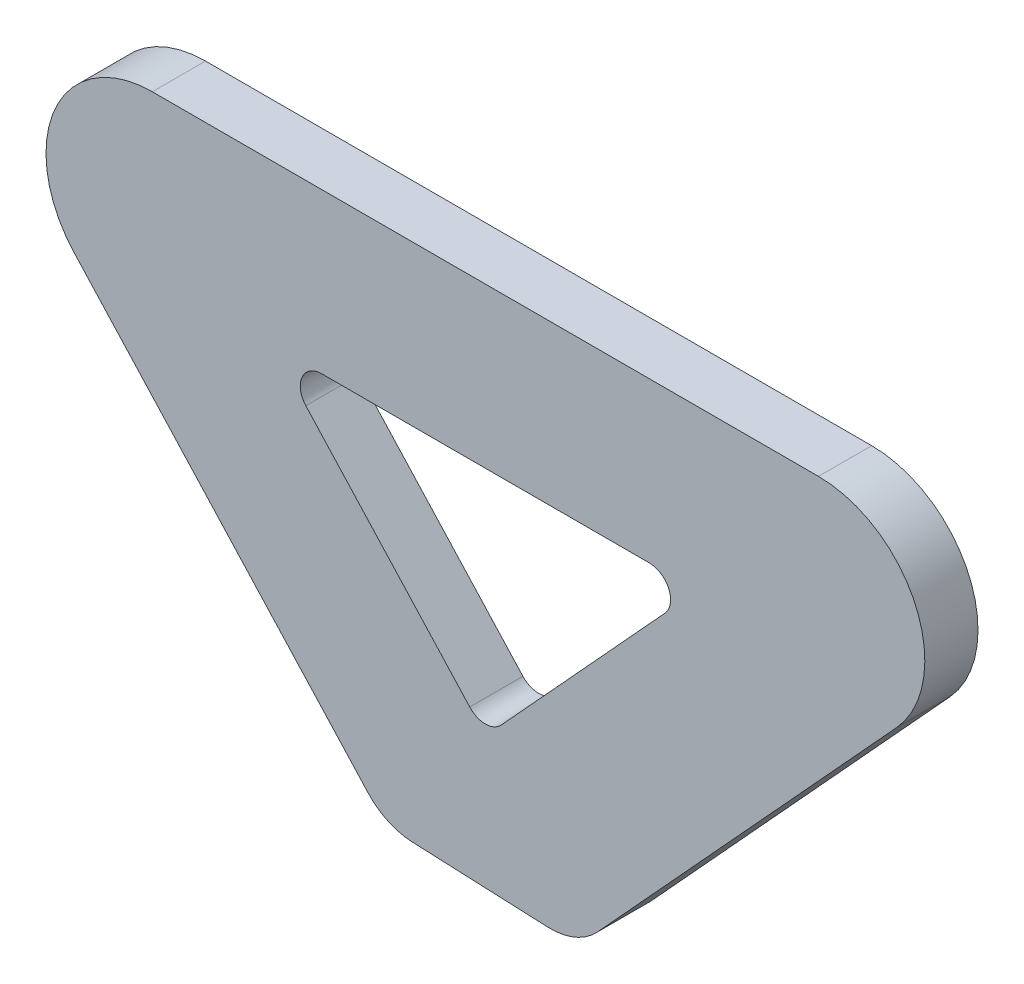
from build123d import *

# Parameters (mm, degrees)
BOSS_EXTRUDE2_DEPTH = 6.35
CHAMFER1_SIZE       = 17.62
CHAMFER1_SIZE2      = 16.260294621
FILLET1_R           = 2.54
FILLET2_R           = 7.62


with BuildPart() as part:
    # Sketch1 → Boss-Extrude2 (new body)
    with BuildSketch(Plane.XY):
        with BuildLine():
            Line((0, -74.917600754), (-49.136391394, -21.278600827))
            ThreePointArc((-49.136391394, -21.278600827), (-51.395766113, -7.584251301), (-39.7716913, 0))
            Line((-39.7716913, 0), (0, 0))
            Line((0, 0), (39.7716913, 0))
            ThreePointArc((39.7716913, 0), (51.395766113, -7.584251301), (49.136391394, -21.278600827))
            Line((49.136391394, -21.278600827), (0, -74.917600754))
        make_face()
        Polygon((0, -46.715449274), (25.343133643, -19.05), (0, -19.05), (-25.343133643, -19.05), align=None, mode=Mode.SUBTRACT)
    extrude(amount=BOSS_EXTRUDE2_DEPTH)

    # Chamfer1
    chamfer1_edges = [part.edges().sort_by_distance(p)[0] for p in [
        (0, -74.917600754, 3.175),
    ]]
    chamfer1_side = [part.faces().sort_by_distance(p)[0] for p in [
        (-24.568195697, -48.098100791, 3.175),
    ]]
    chamfer(chamfer1_edges, length=CHAMFER1_SIZE, length2=CHAMFER1_SIZE2, reference=chamfer1_side[0])

    # Fillet1
    fillet1_edges = [part.edges().sort_by_distance(p)[0] for p in [
        (-25.343133643, -19.05, 3.175),
        (0, -46.715449274, 3.175),
        (25.343133643, -19.05, 3.175),
    ]]
    fillet(fillet1_edges, radius=FILLET1_R)

    # Fillet2
    fillet2_edges = [part.edges().sort_by_distance(p)[0] for p in [
        (10.98350999, -62.927617875, 3.175),
        (-11.901964297, -61.925001096, 3.175),
    ]]
    fillet(fillet2_edges, radius=FILLET2_R)


solid = part.part
